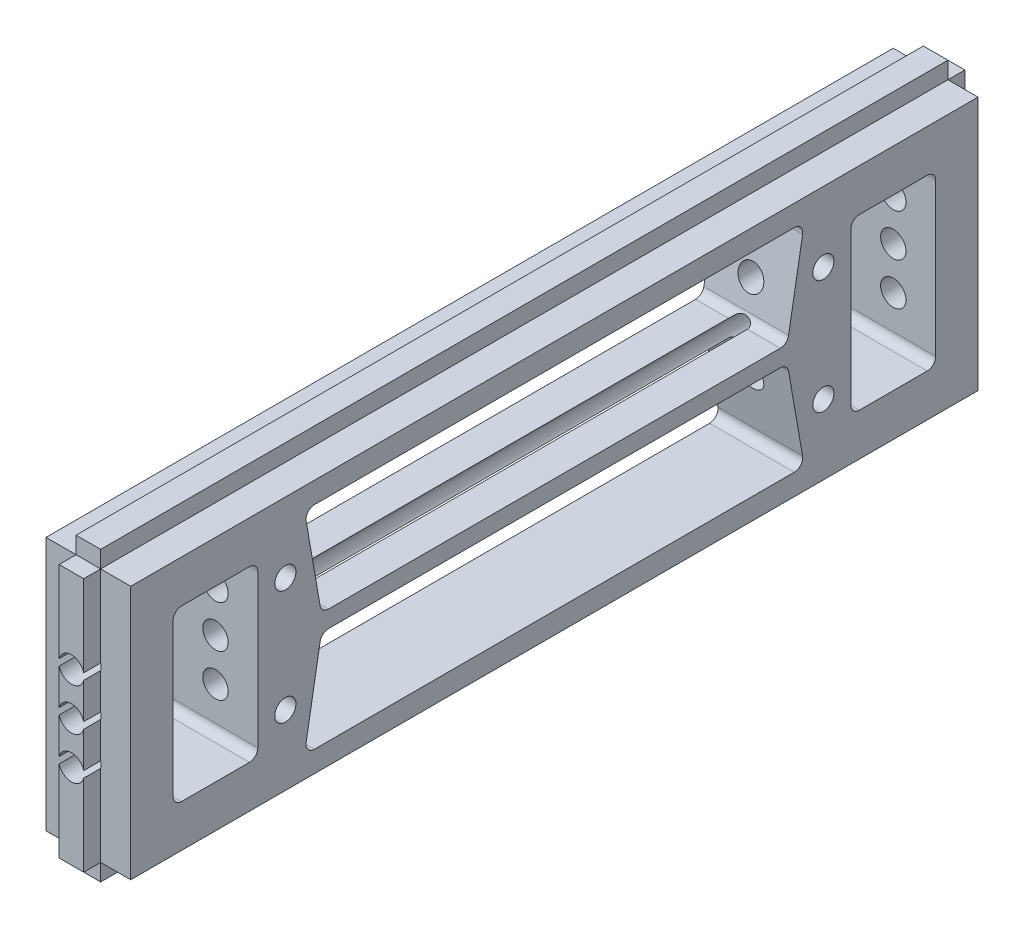
from build123d import *

# Parameters (mm, degrees)
MAKERBEAMFIX_DEPTH               = 50
SKETCH4_R                        = 1.25
HOLEFORHARTINGCONNECTOR_DEPTH    = 54.749418602
FILLET1_R                        = 1
FILLET1_OF_MIRROR1_R             = 1
SKETCH5_W                        = 2.9
SKETCH5_H                        = 30
MAKERBEAMFIXLEFT_DEPTH           = 2
SKETCH6_W                        = 2.9
SKETCH6_H                        = 30
MAKERBEAMFIXRIGHT_DEPTH          = 2
SKETCH7_W                        = 10
SKETCH7_H                        = 20
MAKERBEAMSIDEHOLESFORSCREW_DEPTH = 56.614746246
MAKERBEAMSIDEHOLES_START         = -104
SKETCH8_R                        = 1.5
MAKERBEAMSIDEHOLES_DEPTH         = 104
FILLET2_R                        = 1


with BuildPart() as part:
    # Sketch1 → MakerBeamFix (new, symmetric)
    with BuildSketch(Plane.XY):
        Polygon((-5, -15), (-1.45, -15), (-1.45, -17), (1.45, -17), (1.45, -15), (5, -15), (5, 15), (1.45, 15), (1.45, 17), (-1.45, 17), (-1.45, 15), (-5, 15), align=None)
    extrude(amount=MAKERBEAMFIX_DEPTH, both=True)

    # Sketch4 → HoleForHartingConnector (cut, through all)
    with BuildSketch(Plane.ZY.offset(5)):
        with Locations(Location((-31.75, 6.75, 0), (0, 0, 270))):
            Circle(SKETCH4_R)
        with Locations(Location((31.75, 6.75, 0), (0, 0, 270))):
            Circle(SKETCH4_R)
        Polygon((-29.5, 12.5), (29.5, 12.5), (27.5, 1), (-27.5, 1), align=None)
    holeforhartingconnector = extrude(amount=-HOLEFORHARTINGCONNECTOR_DEPTH, mode=Mode.SUBTRACT)

    # Fillet1
    fillet1_edges = [part.edges().sort_by_distance(p)[0] for p in [
        (0, 1, -27.5),
        (0, 12.5, -29.5),
        (0, 12.5, 29.5),
        (0, 1, 27.5),
    ]]
    fillet(fillet1_edges, radius=FILLET1_R)

    # Mirror1: HoleForHartingConnector across plane
    add(holeforhartingconnector.mirror(Plane.ZX), mode=Mode.SUBTRACT)

    # Fillet1 of Mirror1
    fillet1_of_mirror1_edges = [part.edges().sort_by_distance(p)[0] for p in [
        (0, -1, -27.5),
        (0, -12.5, -29.5),
        (0, -12.5, 29.5),
        (0, -1, 27.5),
    ]]
    fillet(fillet1_of_mirror1_edges, radius=FILLET1_OF_MIRROR1_R)

    # Sketch5 → MakerBeamFixLeft (add)
    with BuildSketch(Plane.XY.offset(50)):
        Rectangle(SKETCH5_W, SKETCH5_H)
    extrude(amount=MAKERBEAMFIXLEFT_DEPTH)

    # Sketch6 → MakerBeamFixRight (add)
    with BuildSketch(Plane(origin=(0, 0, -50), x_dir=(-1, 0, 0), z_dir=(0, 0, -1))):
        Rectangle(SKETCH6_W, SKETCH6_H)
    extrude(amount=MAKERBEAMFIXRIGHT_DEPTH)

    # Sketch7 → MakerBeamSideHolesForScrew (cut, through all)
    with BuildSketch(Plane.ZY.offset(5)):
        with Locations((40, 0)):
            Rectangle(SKETCH7_W, SKETCH7_H)
        with Locations((-40, 0)):
            Rectangle(SKETCH7_W, SKETCH7_H)
    extrude(amount=-MAKERBEAMSIDEHOLESFORSCREW_DEPTH, mode=Mode.SUBTRACT)

    # Sketch8 → MakerBeamSideHoles (cut)
    with BuildSketch(Plane.XY.offset(52).offset(MAKERBEAMSIDEHOLES_START)):
        with Locations((0, -5)):
            Circle(SKETCH8_R)
        Circle(SKETCH8_R)
        with Locations((0, 5)):
            Circle(SKETCH8_R)
    makerbeamsideholes = extrude(amount=MAKERBEAMSIDEHOLES_DEPTH, mode=Mode.SUBTRACT)

    # MakerBeamSideHolesMirror: MakerBeamSideHoles across plane
    add(makerbeamsideholes.mirror(Plane.XY), mode=Mode.SUBTRACT)

    # Fillet2
    fillet2_edges = [part.edges().sort_by_distance(p)[0] for p in [
        (0, 10, 45),
        (0, -10, 45),
        (0, -10, 35),
        (0, 10, 35),
        (0, 10, -35),
        (0, -10, -35),
        (0, -10, -45),
        (0, 10, -45),
    ]]
    fillet(fillet2_edges, radius=FILLET2_R)


solid = part.part
